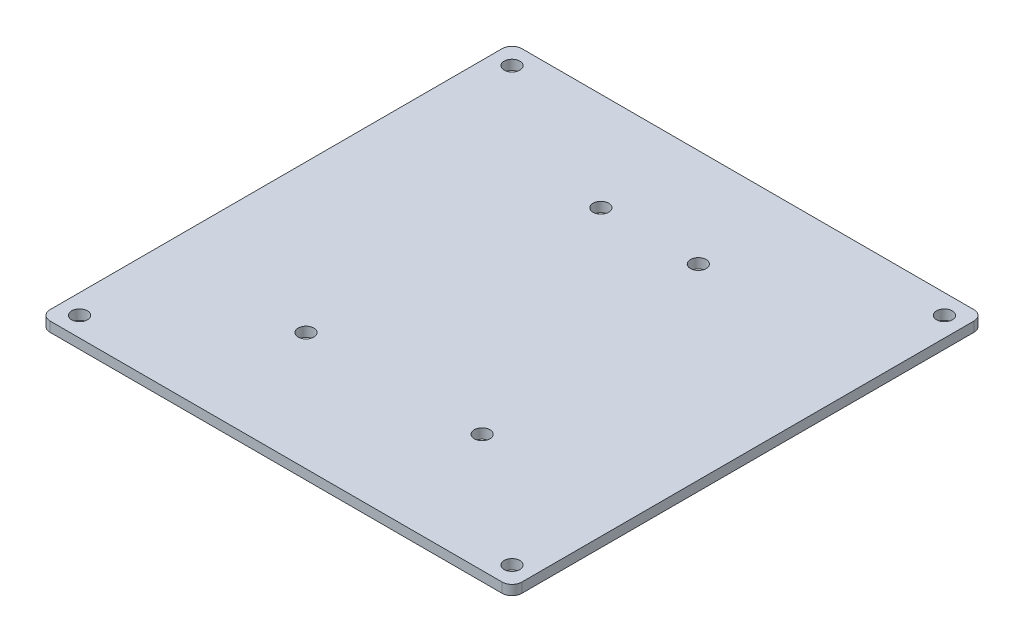
from build123d import *

# Parameters (mm, degrees)
SKETCH2_R           = 5.08
BOSS_EXTRUDE1_DEPTH = 6.35
FILLET1_R           = 6.35
FILLET2_R           = 6.35


with BuildPart() as part:
    # Sketch2 → Boss-Extrude1 (new body)
    with BuildSketch(Plane(origin=(0, 0, 0), x_dir=(1, 0, 0), z_dir=(0, 1, 0))):
        Polygon((-152.4, 152.4), (-152.4, -152.4), (152.4, -152.4), (152.4, 142.494), (152.4, 152.4), (142.494, 152.4), align=None)
        with Locations((-139.7, -139.7)):
            Circle(SKETCH2_R, mode=Mode.SUBTRACT)
        with Locations((-56.896, -76.2)):
            Circle(SKETCH2_R, mode=Mode.SUBTRACT)
        with Locations((139.7, -139.7)):
            Circle(SKETCH2_R, mode=Mode.SUBTRACT)
        with Locations((56.896, -76.2)):
            Circle(SKETCH2_R, mode=Mode.SUBTRACT)
        with Locations((-139.7, 139.7)):
            Circle(SKETCH2_R, mode=Mode.SUBTRACT)
        with Locations((-31.496, 88.9)):
            Circle(SKETCH2_R, mode=Mode.SUBTRACT)
        with Locations((31.496, 88.9)):
            Circle(SKETCH2_R, mode=Mode.SUBTRACT)
        with Locations((139.7, 139.7)):
            Circle(SKETCH2_R, mode=Mode.SUBTRACT)
    extrude(amount=BOSS_EXTRUDE1_DEPTH)

    # Fillet1
    fillet1_edges = [part.edges().sort_by_distance(p)[0] for p in [
        (-152.4, 3.175, 152.4),
    ]]
    fillet(fillet1_edges, radius=FILLET1_R)

    # Fillet2
    fillet2_edges = [part.edges().sort_by_distance(p)[0] for p in [
        (-152.4, 3.175, -152.4),
        (152.4, 3.175, -152.4),
        (152.4, 3.175, 152.4),
    ]]
    fillet(fillet2_edges, radius=FILLET2_R)


solid = part.part
